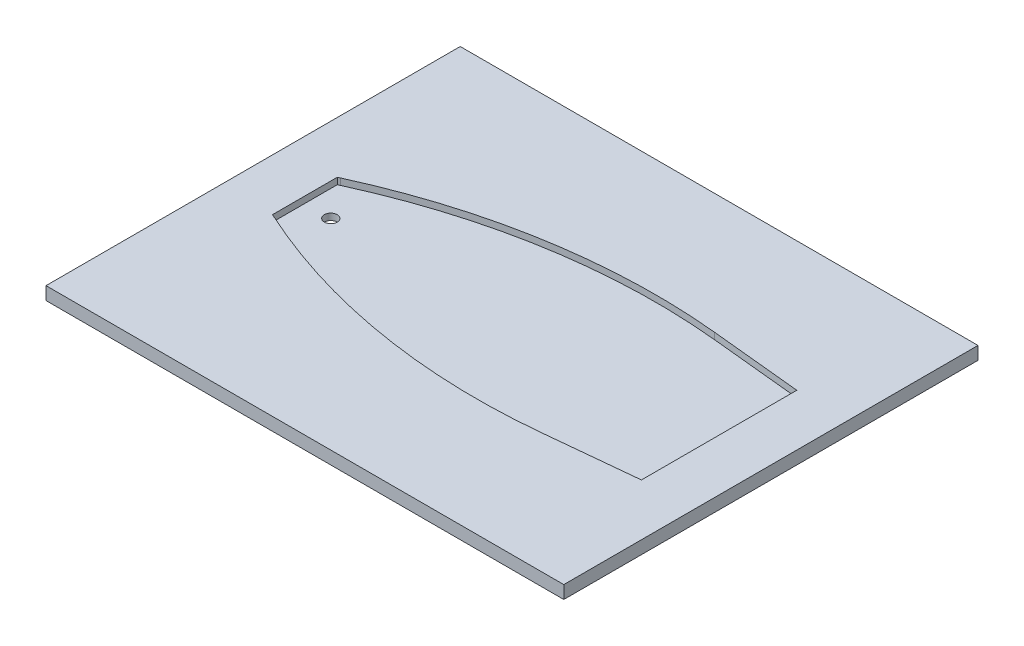
from build123d import *

# Parameters (mm, degrees)
SKETCH1_W           = 254
SKETCH1_H           = 203.2
BOSS_EXTRUDE1_DEPTH = 6.35
SKETCH2_R           = 3.175
CUT_EXTRUDE1_DEPTH  = 6.35
CUT_EXTRUDE3_DEPTH  = 3.175
FILLET2_R           = 304.8


with BuildPart() as part:
    # Sketch1 → Boss-Extrude1 (new body)
    with BuildSketch(Plane(origin=(0, 0, 0), x_dir=(1, 0, 0), z_dir=(0, 1, 0))):
        Rectangle(SKETCH1_W, SKETCH1_H)
    extrude(amount=BOSS_EXTRUDE1_DEPTH)

    # Sketch2 → Cut-Extrude1 (cut)
    with BuildSketch(Plane(origin=(0, 6.35, 0), x_dir=(1, 0, 0), z_dir=(0, 1, 0))):
        with Locations((-88.9, 0)):
            Circle(SKETCH2_R)
    extrude(amount=-CUT_EXTRUDE1_DEPTH, mode=Mode.SUBTRACT)

    # Sketch5 → Cut-Extrude3 (cut)
    with BuildSketch(Plane(origin=(0, 6.35, 0), x_dir=(1, 0, 0), z_dir=(0, 1, 0))):
        Polygon((-101.6, 15.875), (-101.6, -15.875), (-25.4, -50.8), (101.6, -38.1), (101.6, 38.1), (-25.4, 50.8), align=None)
    extrude(amount=-CUT_EXTRUDE3_DEPTH, mode=Mode.SUBTRACT)

    # Fillet2
    fillet2_edges = [part.edges().sort_by_distance(p)[0] for p in [
        (-25.4, 4.7625, -50.8),
        (-25.4, 4.7625, 50.8),
    ]]
    fillet(fillet2_edges, radius=FILLET2_R)


solid = part.part
